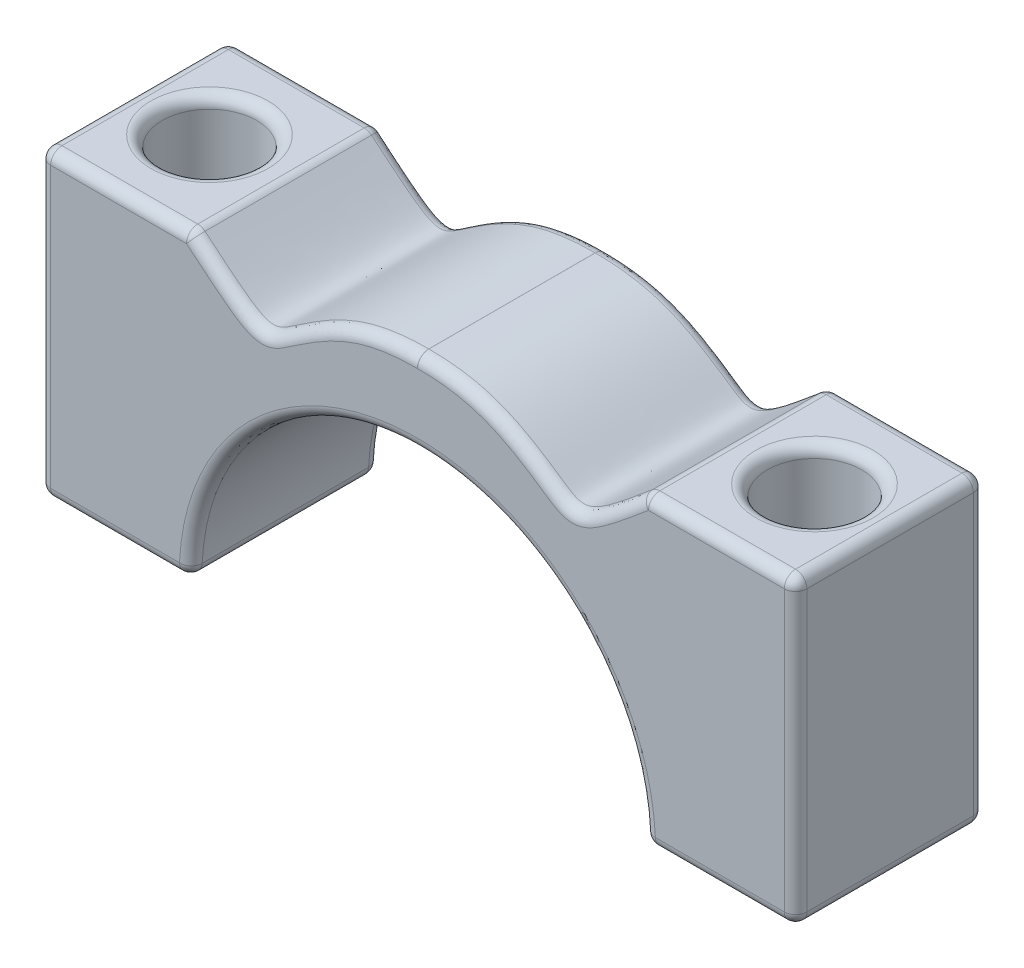
from build123d import *

# Parameters (mm, degrees)
BOSS_EXTRUDE1_DEPTH = 5
CUT_EXTRUDE2_REACH  = 10
SKETCH2_R           = 1.25
FILLET1_R           = 0.3


with BuildPart() as part:
    # Sketch1 → Boss-Extrude1 (new body)
    with BuildSketch(Plane.XY):
        with BuildLine():
            Line((-188.444605556, 82.173113522), (-188.444605556, 90.173113522))
            Line((-188.444605556, 90.173113522), (-184.444605556, 90.173113522))
            add(Edge.make_bspline(
                [(-184.444605556, 90.173113522), (-182.710524928, 88.718795458), (-182.58030034, 88.671840822), (-180.488649067, 90.200558533), (-178.973443566, 90.368843801), (-178.444605556, 90.366502261)],
                knots=[0, 0, 0, 0, 0.237143327, 0.40682514, 0.498389752, 0.498389752, 0.498389752, 0.498389752], degree=3))
            add(Edge.make_bspline(
                [(-172.444605556, 90.173113522), (-174.178686184, 88.718795458), (-174.308910772, 88.671840822), (-176.400562045, 90.200558533), (-177.915767547, 90.368843801), (-178.444605556, 90.366502261)],
                knots=[0, 0, 0, 0, 0.237143327, 0.40682514, 0.498389752, 0.498389752, 0.498389752, 0.498389752], degree=3))
            Line((-172.444605556, 90.173113522), (-168.444605556, 90.173113522))
            Line((-168.444605556, 90.173113522), (-168.444605556, 82.173113522))
            Line((-168.444605556, 82.173113522), (-172.444605556, 82.173113522))
            ThreePointArc((-172.444605556, 82.173113522), (-178.444605556, 88.173113522), (-184.444605556, 82.173113522))
            Line((-184.444605556, 82.173113522), (-188.444605556, 82.173113522))
        make_face()
    extrude(amount=BOSS_EXTRUDE1_DEPTH)

    # Sketch2 → Cut-Extrude2 (cut, up to next)
    with BuildSketch(Plane(origin=(0, 90.173113522, 0), x_dir=(1, 0, 0), z_dir=(0, 1, 0)), mode=Mode.PRIVATE) as cut_extrude2_sk1:
        with Locations((-186.444605556, -2.5)):
            Circle(SKETCH2_R)
    cut_extrude2_tool1 = extrude(cut_extrude2_sk1.sketch, amount=-CUT_EXTRUDE2_REACH, mode=Mode.PRIVATE) & part.part
    add(cut_extrude2_tool1.solids().sort_by_distance((-186.444606, 90.173114, 2.5))[0], mode=Mode.SUBTRACT)
    # Sketch2 → Cut-Extrude2 (cut, up to next)
    with BuildSketch(Plane(origin=(0, 90.173113522, 0), x_dir=(1, 0, 0), z_dir=(0, 1, 0)), mode=Mode.PRIVATE) as cut_extrude2_sk2:
        with Locations((-170.444605556, -2.5)):
            Circle(SKETCH2_R)
    cut_extrude2_tool2 = extrude(cut_extrude2_sk2.sketch, amount=-CUT_EXTRUDE2_REACH, mode=Mode.PRIVATE) & part.part
    add(cut_extrude2_tool2.solids().sort_by_distance((-170.444606, 90.173114, 2.5))[0], mode=Mode.SUBTRACT)

    # Fillet1
    fillet1_edges = [part.edges().sort_by_distance(p)[0] for p in [
        (-170.444605556, 82.173113522, 5),
        (-170.444605556, 90.173113522, 0),
        (-168.444605556, 86.173113522, 0),
        (-170.444605556, 82.173113522, 0),
        (-178.444605556, 88.173113522, 0),
        (-186.444605556, 82.173113522, 0),
        (-168.444605556, 86.173113522, 5),
        (-188.444605556, 82.173113522, 2.5),
        (-188.444605556, 90.173113522, 2.5),
        (-184.444605556, 90.173113522, 2.5),
        (-178.444605556, 90.366502261, 2.5),
        (-172.444605556, 90.173113522, 2.5),
        (-168.444605556, 90.173113522, 2.5),
        (-168.444605556, 82.173113522, 2.5),
        (-172.444605556, 82.173113522, 2.5),
        (-184.444605556, 82.173113522, 2.5),
        (-170.444605556, 90.173113522, 5),
        (-175.265152654, 89.373543886, 5),
        (-181.624058458, 89.373543886, 5),
        (-186.444605556, 90.173113522, 5),
        (-171.694605556, 90.173113522, 2.5),
        (-171.694605556, 82.173113522, 2.5),
        (-188.444605556, 86.173113522, 5),
        (-187.694605556, 90.173113522, 2.5),
        (-187.694605556, 82.173113522, 2.5),
        (-186.444605556, 82.173113522, 5),
        (-178.444605556, 88.173113522, 5),
        (-188.444605556, 86.173113522, 0),
        (-186.444605556, 90.173113522, 0),
        (-181.624058458, 89.373543886, 0),
        (-175.265152654, 89.373543886, 0),
    ]]
    fillet(fillet1_edges, radius=FILLET1_R)


solid = part.part
